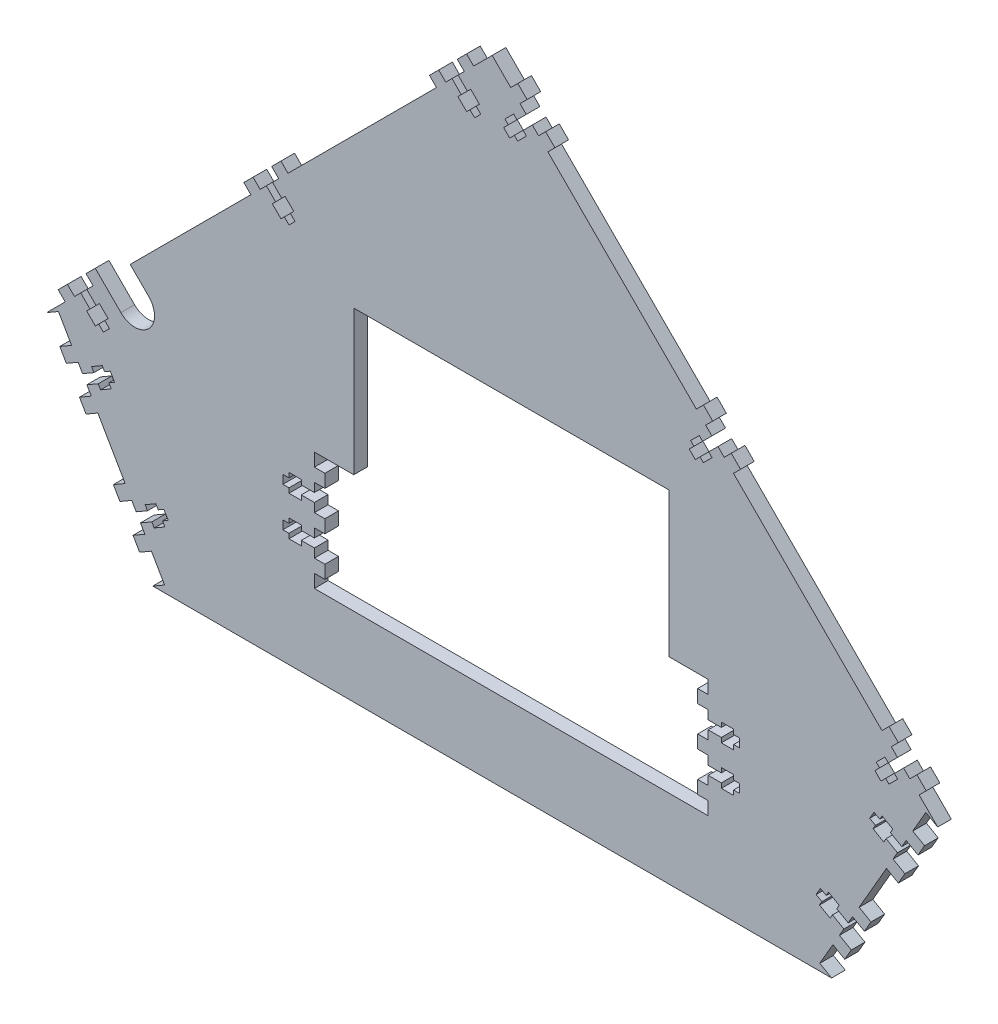
from build123d import *

# Parameters (mm, degrees)
BOSS_EXTRUDE1_DEPTH = 6.604
CUT_EXTRUDE1_DEPTH  = 374.05550758
CUT_EXTRUDE2_DEPTH  = 374.05550758
CUT_EXTRUDE3_DEPTH  = 374.05550758
SKETCH7_W           = 5.08
SKETCH7_H           = 6.35
BOSS_EXTRUDE2_DEPTH = 6.604
MOVE_FACE2_BY       = 1.778
MOVE_FACE2_2_BY     = 1.778
MOVE_FACE2_3_BY     = 1.778
MOVE_FACE2_4_BY     = 1.778
MOVE_FACE2_5_BY     = 1.778
MOVE_FACE2_6_BY     = 1.778
MOVE_FACE2_7_BY     = 1.778
MOVE_FACE2_8_BY     = 1.778
CUT_EXTRUDE4_DEPTH  = 374.05550758


with BuildPart() as part:
    # Sketch1 → Boss-Extrude1 (new body)
    with BuildSketch(Plane.XY):
        Polygon((0, 304.426146906), (215.526146906, 88.9), (164.199707975, 0), (0, 0), (-164.199707975, 0), (-215.526146906, 88.9), align=None)
    extrude(amount=BOSS_EXTRUDE1_DEPTH)

    # Sketch2 → Cut-Extrude1 (cut, through all)
    with BuildSketch(Plane.XY.offset(6.604)):
        Polygon((-66.955389821, 165.1), (85.444610179, 165.1), (85.444610179, 95.25), (104.494610179, 95.25), (104.494610179, 38.1), (85.444610179, 38.1), (-66.955389821, 38.1), (-86.005389821, 38.1), (-86.005389821, 95.25), (-66.955389821, 95.25), align=None)
    extrude(amount=-CUT_EXTRUDE1_DEPTH, mode=Mode.SUBTRACT)

    # Sketch3 → Cut-Extrude2 (cut, through all)
    with BuildSketch(Plane.XY.offset(6.604)):
        Polygon((-209.806915139, 92.202), (-215.526146906, 88.9), (-164.199707975, 0), (-158.480476208, 3.302), align=None)
        Polygon((158.480476208, 3.302), (209.806915139, 92.202), (215.526146906, 88.9), (164.199707975, 0), align=None)
    extrude(amount=-CUT_EXTRUDE2_DEPTH, mode=Mode.SUBTRACT)

    # Sketch6 → Cut-Extrude3 (cut, through all)
    with BuildSketch(Plane.XY.offset(6.604)):
        Polygon((-11.997622178, 283.448268607), (-16.487750238, 287.938396667), (-19.433274246, 284.99287266), (-14.943146185, 280.502744599), (-16.559592287, 278.886298497), (-12.356832423, 274.683538633), (-10.740386321, 276.299984734), (-8.477361778, 274.036960192), (-5.531837771, 276.9824842), (-7.794862313, 279.245508742), (-6.178416211, 280.861954844), (-10.381176076, 285.064714709), align=None)
        Polygon((-101.800183388, 193.645707396), (-106.290311449, 198.135835457), (-109.235835457, 195.190311449), (-104.745707396, 190.700183388), (-106.362153498, 189.083737287), (-102.159393633, 184.880977422), (-100.542947531, 186.497423524), (-98.279922989, 184.234398981), (-95.334398981, 187.179922989), (-97.597423524, 189.442947531), (-95.980977422, 191.059393633), (-100.183737287, 195.262153498), align=None)
        Polygon((-199.038396667, 105.387750238), (-194.548268607, 100.897622178), (-196.164714709, 99.281176076), (-191.961954844, 95.078416211), (-190.345508742, 96.694862313), (-188.0824842, 94.431837771), (-185.136960192, 97.377361778), (-187.399984734, 99.640386321), (-185.783538633, 101.256832423), (-189.986298497, 105.459592287), (-191.602744599, 103.843146185), (-196.09287266, 108.333274246), align=None)
        Polygon((-192.649053825, 75.183712455), (-198.148315139, 72.008712455), (-196.065515139, 68.401197033), (-190.566253825, 71.576197033), (-189.423253825, 69.59646296), (-184.275945235, 72.56826296), (-185.418945235, 74.547997033), (-182.647317533, 76.148197033), (-184.730117533, 79.755712455), (-187.501745235, 78.155512455), (-188.644745235, 80.135246528), (-193.792053825, 77.163446528), align=None)
        Polygon((-166.722614894, 30.277802967), (-172.221876208, 27.102802967), (-170.139076208, 23.495287545), (-164.639814894, 26.670287545), (-163.496814894, 24.690553472), (-158.349506304, 27.662353472), (-159.492506304, 29.642087545), (-156.720878602, 31.242287545), (-158.803678602, 34.849802967), (-161.575306304, 33.249602967), (-162.718306304, 35.22933704), (-167.865614894, 32.25753704), align=None)
        Polygon((10.381176076, 285.064714709), (6.178416211, 280.861954844), (7.794862313, 279.245508742), (5.531837771, 276.9824842), (8.477361778, 274.036960192), (10.740386321, 276.299984734), (12.356832423, 274.683538633), (16.559592287, 278.886298497), (14.943146185, 280.502744599), (19.433274246, 284.99287266), (16.487750238, 287.938396667), (11.997622178, 283.448268607), align=None)
        Polygon((106.290311449, 198.135835457), (101.800183388, 193.645707396), (100.183737287, 195.262153498), (95.980977422, 191.059393633), (97.597423524, 189.442947531), (95.334398981, 187.179922989), (98.279922989, 184.234398981), (100.542947531, 186.497423524), (102.159393633, 184.880977422), (106.362153498, 189.083737287), (104.745707396, 190.700183388), (109.235835457, 195.190311449), align=None)
        Polygon((194.548268607, 100.897622178), (199.038396667, 105.387750238), (196.09287266, 108.333274246), (191.602744599, 103.843146185), (189.986298497, 105.459592287), (185.783538633, 101.256832423), (187.399984734, 99.640386321), (185.136960192, 97.377361778), (188.0824842, 94.431837771), (190.345508742, 96.694862313), (191.961954844, 95.078416211), (196.164714709, 99.281176076), align=None)
        Polygon((188.644745235, 80.135246528), (187.501745235, 78.155512455), (184.730117533, 79.755712455), (182.647317533, 76.148197033), (185.418945235, 74.547997033), (184.275945235, 72.56826296), (189.423253825, 69.59646296), (190.566253825, 71.576197033), (196.065515139, 68.401197033), (198.148315139, 72.008712455), (192.649053825, 75.183712455), (193.792053825, 77.163446528), align=None)
        Polygon((161.575306304, 33.249602967), (158.803678602, 34.849802967), (156.720878602, 31.242287545), (159.492506304, 29.642087545), (158.349506304, 27.662353472), (163.496814894, 24.690553472), (164.639814894, 26.670287545), (170.139076208, 23.495287545), (172.221876208, 27.102802967), (166.722614894, 30.277802967), (167.865614894, 32.25753704), (162.718306304, 35.22933704), align=None)
        Polygon((-86.005389821, 78.2828), (-92.355389821, 78.2828), (-92.355389821, 80.5688), (-98.298989821, 80.5688), (-98.298989821, 78.2828), (-101.245389821, 78.2828), (-101.245389821, 74.1172), (-98.298989821, 74.1172), (-98.298989821, 71.8312), (-92.355389821, 71.8312), (-92.355389821, 74.1172), (-86.005389821, 74.1172), align=None)
        Polygon((-92.355389821, 61.5188), (-98.298989821, 61.5188), (-98.298989821, 59.2328), (-101.245389821, 59.2328), (-101.245389821, 55.0672), (-98.298989821, 55.0672), (-98.298989821, 52.7812), (-92.355389821, 52.7812), (-92.355389821, 55.0672), (-86.005389821, 55.0672), (-86.005389821, 59.2328), (-92.355389821, 59.2328), align=None)
        Polygon((110.844610179, 78.2828), (104.494610179, 78.2828), (104.494610179, 74.1172), (110.844610179, 74.1172), (110.844610179, 71.8312), (116.788210179, 71.8312), (116.788210179, 74.1172), (119.734610179, 74.1172), (119.734610179, 78.2828), (116.788210179, 78.2828), (116.788210179, 80.5688), (110.844610179, 80.5688), align=None)
        Polygon((110.844610179, 59.2328), (104.494610179, 59.2328), (104.494610179, 55.0672), (110.844610179, 55.0672), (110.844610179, 52.7812), (116.788210179, 52.7812), (116.788210179, 55.0672), (119.734610179, 55.0672), (119.734610179, 59.2328), (116.788210179, 59.2328), (116.788210179, 61.5188), (110.844610179, 61.5188), align=None)
    extrude(amount=-CUT_EXTRUDE3_DEPTH, mode=Mode.SUBTRACT)

    # Sketch7 → Boss-Extrude2 (add)
    with BuildSketch(Plane.XY.offset(6.604)):
        Polygon((-12.392753447, 298.858388111), (-8.980256121, 295.445890785), (-13.470384182, 290.955762724), (-16.882881508, 294.36826005), align=None)
        Polygon((-22.450640303, 281.975506603), (-25.863137629, 285.388003929), (-30.353265689, 280.897875868), (-26.940768363, 277.485378542), align=None)
        Polygon((-102.195314658, 209.0558269), (-98.782817332, 205.643329574), (-103.272945392, 201.153201513), (-106.685442718, 204.565698839), align=None)
        Polygon((-112.253201513, 192.172945392), (-115.665698839, 195.585442718), (-120.1558269, 191.095314658), (-116.743329574, 187.682817332), align=None)
        Polygon((-191.997875868, 119.253265689), (-188.585378542, 115.840768363), (-193.075506603, 111.350640303), (-196.488003929, 114.763137629), align=None)
        Polygon((-202.055762724, 102.370384182), (-205.46826005, 105.782881508), (-209.958388111, 101.292753447), (-206.545890785, 97.880256121), align=None)
        Polygon((-207.636353738, 78.790477372), (-203.456915139, 81.203477372), (-200.281915139, 75.704216058), (-204.461353738, 73.291216058), align=None)
        Polygon((-193.931915139, 64.70569343), (-198.111353738, 62.29269343), (-194.936353738, 56.793432116), (-190.756915139, 59.206432116), align=None)
        Polygon((-181.709914807, 33.884567884), (-177.530476208, 36.297567884), (-174.355476208, 30.79830657), (-178.534914807, 28.38530657), align=None)
        Polygon((-168.005476208, 19.799783942), (-172.184914807, 17.386783942), (-169.009914807, 11.887522628), (-164.830476208, 14.300522628), align=None)
        Polygon((169.009914807, 11.887522628), (164.830476208, 14.300522628), (168.005476208, 19.799783942), (172.184914807, 17.386783942), align=None)
        Polygon((174.355476208, 30.79830657), (178.534914807, 28.38530657), (181.709914807, 33.884567884), (177.530476208, 36.297567884), align=None)
        Polygon((194.936353738, 56.793432116), (190.756915139, 59.206432116), (193.931915139, 64.70569343), (198.111353738, 62.29269343), align=None)
        Polygon((207.636353738, 78.790477372), (203.456915139, 81.203477372), (200.281915139, 75.704216058), (204.461353738, 73.291216058), align=None)
        Polygon((209.958388111, 101.292753447), (206.545890785, 97.880256121), (202.055762724, 102.370384182), (205.46826005, 105.782881508), align=None)
        Polygon((193.075506603, 111.350640303), (196.488003929, 114.763137629), (191.997875868, 119.253265689), (188.585378542, 115.840768363), align=None)
        Polygon((120.1558269, 191.095314658), (116.743329574, 187.682817332), (112.253201513, 192.172945392), (115.665698839, 195.585442718), align=None)
        Polygon((106.685442718, 204.565698839), (102.195314658, 209.0558269), (98.782817332, 205.643329574), (103.272945392, 201.153201513), align=None)
        Polygon((25.863137629, 285.388003929), (30.353265689, 280.897875868), (26.940768363, 277.485378542), (22.450640303, 281.975506603), align=None)
        Polygon((16.882881508, 294.36826005), (12.392753447, 298.858388111), (8.980256121, 295.445890785), (13.470384182, 290.955762724), align=None)
        with Locations((-83.465389821, 85.725)):
            Rectangle(SKETCH7_W, SKETCH7_H)
        with Locations((-83.465389821, 66.675)):
            Rectangle(SKETCH7_W, SKETCH7_H)
        with Locations((-83.465389821, 47.625)):
            Rectangle(SKETCH7_W, SKETCH7_H)
        with Locations((101.954610179, 85.725)):
            Rectangle(SKETCH7_W, SKETCH7_H)
        with Locations((101.954610179, 66.675)):
            Rectangle(SKETCH7_W, SKETCH7_H)
        with Locations((101.954610179, 47.625)):
            Rectangle(SKETCH7_W, SKETCH7_H)
    extrude(amount=-BOSS_EXTRUDE2_DEPTH)

    # Move Face2: a face moved outward by 1.778
    extrude(part.faces().sort_by_distance((206.048853738, 76.040846715, 3.302))[0], amount=MOVE_FACE2_BY, dir=(0.866025404, -0.5, 0))

    # Move Face2 2: a face moved outward by 1.778
    extrude(part.faces().sort_by_distance((196.523853738, 59.543062773, 3.302))[0], amount=MOVE_FACE2_2_BY, dir=(0.866025404, -0.5, 0))

    # Move Face2 3: a face moved outward by 1.778
    extrude(part.faces().sort_by_distance((170.597414807, 14.637153285, 3.302))[0], amount=MOVE_FACE2_3_BY, dir=(0.866025404, -0.5, 0))

    # Move Face2 4: a face moved outward by 1.778
    extrude(part.faces().sort_by_distance((180.122414807, 31.134937227, 3.302))[0], amount=MOVE_FACE2_4_BY, dir=(0.866025404, -0.5, 0))

    # Move Face2 5: a face moved outward by 1.778
    extrude(part.faces().sort_by_distance((-206.048853738, 76.040846715, 3.302))[0], amount=MOVE_FACE2_5_BY, dir=(-0.866025404, -0.5, 0))

    # Move Face2 6: a face moved outward by 1.778
    extrude(part.faces().sort_by_distance((-196.523853738, 59.543062773, 3.302))[0], amount=MOVE_FACE2_6_BY, dir=(-0.866025404, -0.5, 0))

    # Move Face2 7: a face moved outward by 1.778
    extrude(part.faces().sort_by_distance((-180.122414807, 31.134937227, 3.302))[0], amount=MOVE_FACE2_7_BY, dir=(-0.866025404, -0.5, 0))

    # Move Face2 8: a face moved outward by 1.778
    extrude(part.faces().sort_by_distance((-170.597414807, 14.637153285, 3.302))[0], amount=MOVE_FACE2_8_BY, dir=(-0.866025404, -0.5, 0))

    # Sketch8 → Cut-Extrude4 (cut, through all)
    with BuildSketch(Plane.XY.offset(6.604)):
        with BuildLine():
            Line((-175.114994361, 129.311152545), (-166.13473824, 120.330896424))
            ThreePointArc((-166.13473824, 120.330896424), (-166.13473824, 106.860512242), (-179.605122421, 106.860512242))
            Line((-179.605122421, 106.860512242), (-188.585378542, 115.840768363))
            Line((-188.585378542, 115.840768363), (-175.114994361, 129.311152545))
        make_face()
    extrude(amount=-CUT_EXTRUDE4_DEPTH, mode=Mode.SUBTRACT)


solid = part.part
